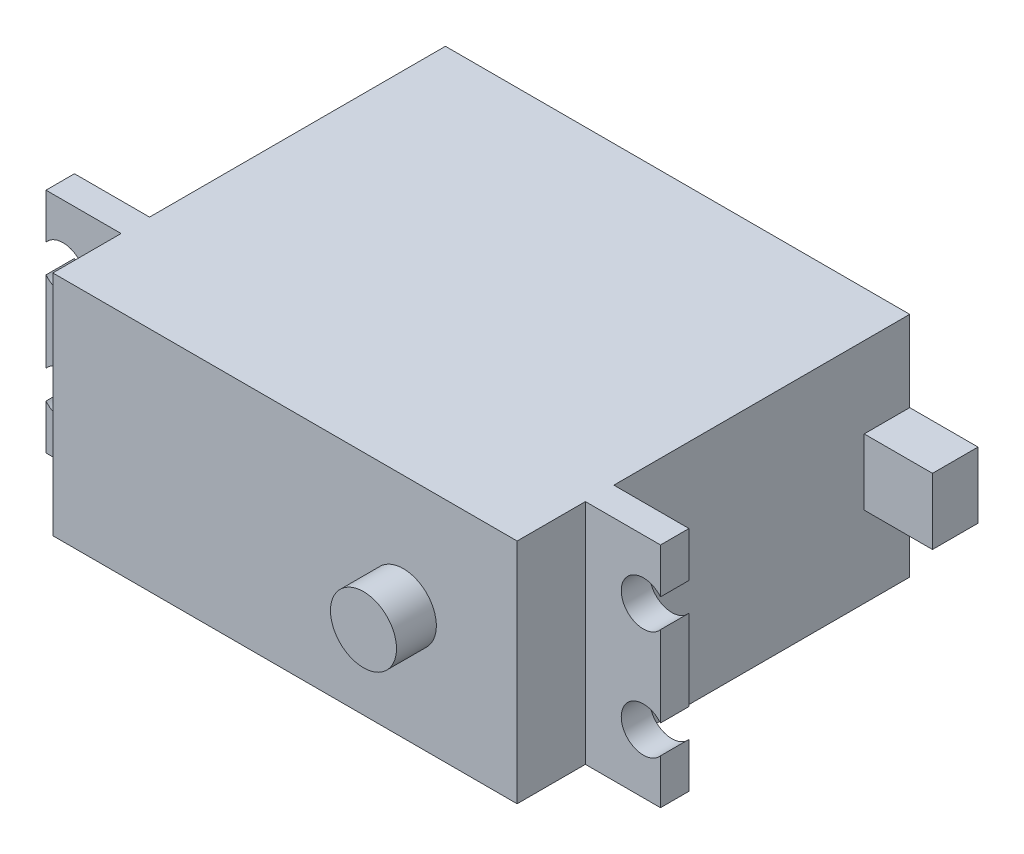
from build123d import *

# Parameters (mm, degrees)
SKETCH1_W           = 54
SKETCH1_H           = 20
BOSS_EXTRUDE1_DEPTH = 2.5
SKETCH3_R           = 1.95
CUT_EXTRUDE1_DEPTH  = 2.5
SKETCH4_W           = 40.8
SKETCH4_H           = 20
BOSS_EXTRUDE2_DEPTH = 6
SKETCH5_W           = 40.8
SKETCH5_H           = 20
BOSS_EXTRUDE3_DEPTH = 26
SKETCH6_R           = 2.9
BOSS_EXTRUDE4_DEPTH = 3.5
SKETCH7_W           = 4
SKETCH7_H           = 5.8
BOSS_EXTRUDE5_DEPTH = 6


with BuildPart() as part:
    # Sketch1 → Boss-Extrude1 (new body)
    with BuildSketch(Plane.XY):
        Rectangle(SKETCH1_W, SKETCH1_H)
    extrude(amount=BOSS_EXTRUDE1_DEPTH)

    # Sketch3 → Cut-Extrude1 (cut)
    with BuildSketch(Plane.XY.offset(2.5)):
        with Locations((-25.5, 4.8)):
            Circle(SKETCH3_R)
        with Locations((-25.5, -4.8)):
            Circle(SKETCH3_R)
        with Locations((25.5, -4.8)):
            Circle(SKETCH3_R)
        with Locations((25.5, 4.8)):
            Circle(SKETCH3_R)
    extrude(amount=-CUT_EXTRUDE1_DEPTH, mode=Mode.SUBTRACT)

    # Sketch4 → Boss-Extrude2 (add)
    with BuildSketch(Plane.XY.offset(2.5)):
        Rectangle(SKETCH4_W, SKETCH4_H)
    extrude(amount=BOSS_EXTRUDE2_DEPTH)

    # Sketch5 → Boss-Extrude3 (add)
    with BuildSketch(Plane(origin=(0, 0, 0), x_dir=(-1, 0, 0), z_dir=(0, 0, -1))):
        Rectangle(SKETCH5_W, SKETCH5_H)
    extrude(amount=BOSS_EXTRUDE3_DEPTH)

    # Sketch6 → Boss-Extrude4 (add)
    with BuildSketch(Plane.XY.offset(8.5)):
        with Locations((10.4, 0)):
            Circle(SKETCH6_R)
    extrude(amount=BOSS_EXTRUDE4_DEPTH)

    # Sketch7 → Boss-Extrude5 (add)
    with BuildSketch(Plane(origin=(20.4, 0, 0), x_dir=(0, 0, -1), z_dir=(1, 0, 0))):
        with Locations((24, 0)):
            Rectangle(SKETCH7_W, SKETCH7_H)
    extrude(amount=BOSS_EXTRUDE5_DEPTH)


solid = part.part
